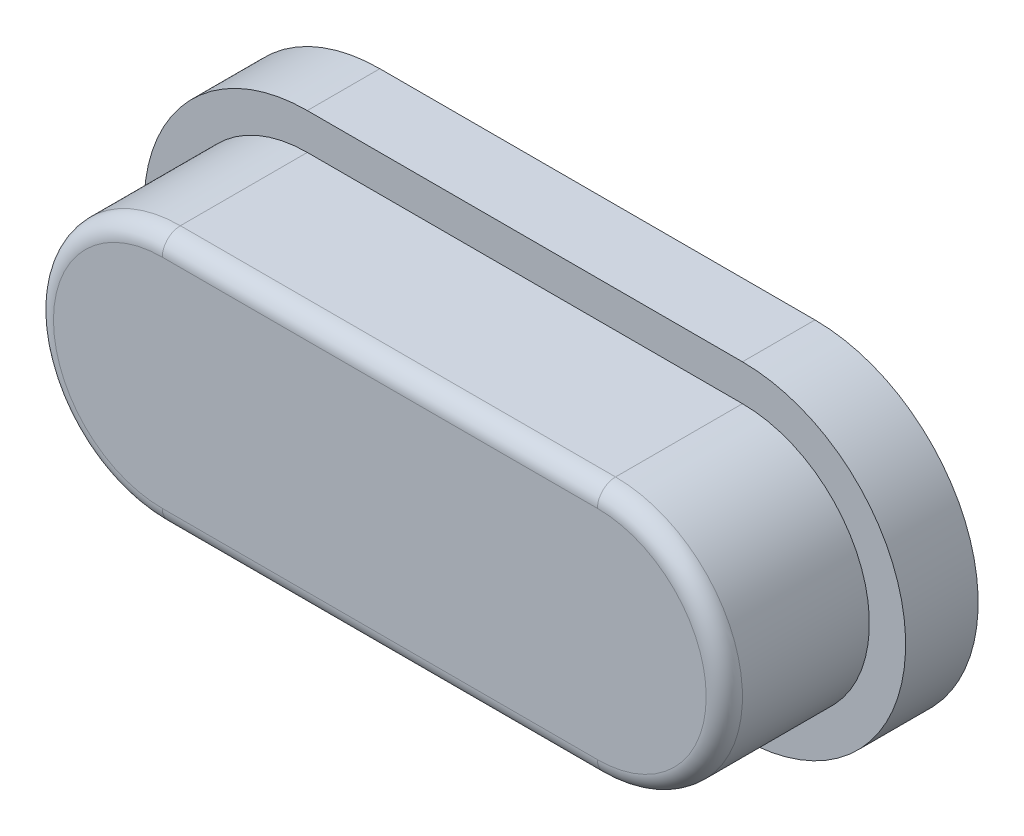
from build123d import *

# Parameters (mm, degrees)
BOSS_EXTRU_1_DEPTH = 2
BOSS_EXTRU_2_DEPTH = 1
CONG_1_R           = 0.25


with BuildPart() as part:
    # Esquisse1 → Boss.-Extru.1 (new body)
    with BuildSketch(Plane.XY):
        with BuildLine():
            Line((-3, 1.75), (3, 1.75))
            ThreePointArc((3, 1.75), (4.75, 0), (3, -1.75))
            Line((3, -1.75), (-3, -1.75))
            ThreePointArc((-3, -1.75), (-4.75, 0), (-3, 1.75))
        make_face()
    extrude(amount=BOSS_EXTRU_1_DEPTH)

    # Esquisse3 → Boss.-Extru.2 (add)
    with BuildSketch(Plane.XY):
        with BuildLine():
            Line((-3, 2.25), (3, 2.25))
            ThreePointArc((3, 2.25), (5.25, 0), (3, -2.25))
            Line((3, -2.25), (-3, -2.25))
            ThreePointArc((-3, -2.25), (-5.25, 0), (-3, 2.25))
        make_face()
    extrude(amount=-BOSS_EXTRU_2_DEPTH)

    # Congé1
    cong_1_edges = [part.edges().sort_by_distance(p)[0] for p in [
        (4.75, 0, 2),
        (0, 1.75, 2),
        (-4.75, 0, 2),
        (0, -1.75, 2),
    ]]
    fillet(cong_1_edges, radius=CONG_1_R)


solid = part.part
